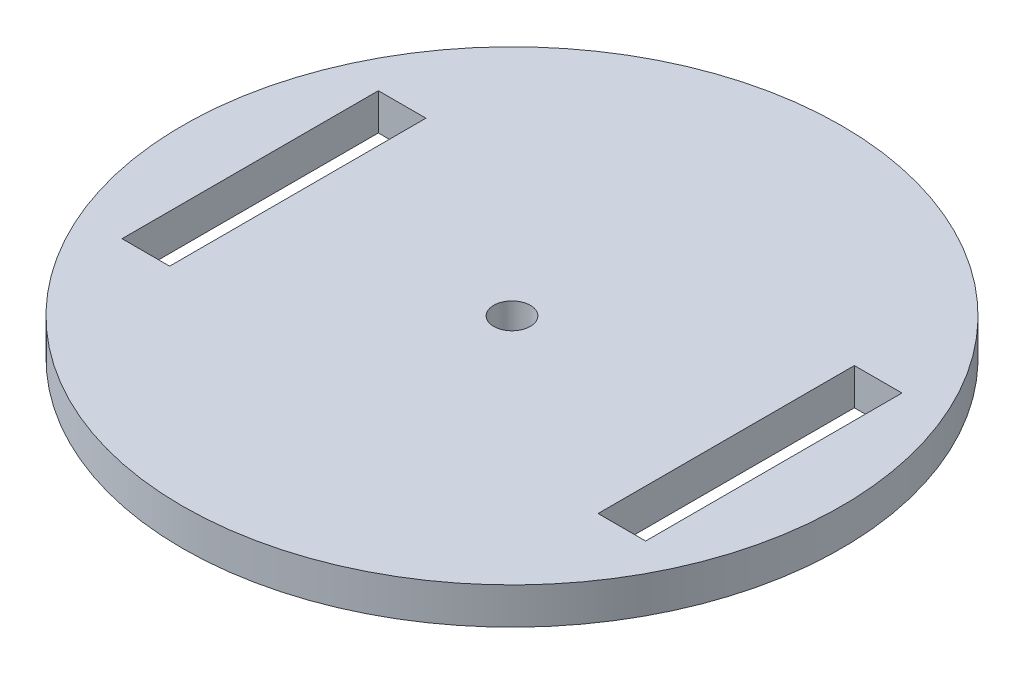
from build123d import *

# Parameters (mm, degrees)
SKETCH1_R           = 90
SKETCH1_W           = 13
SKETCH1_H           = 70
BOSS_EXTRUDE1_DEPTH = 10
CUT_EXTRUDE1_REACH  = 12
SKETCH2_R           = 5


with BuildPart() as part:
    # Sketch1 → Boss-Extrude1 (new body)
    with BuildSketch(Plane(origin=(0, 0, 0), x_dir=(1, 0, 0), z_dir=(0, 1, 0))):
        Circle(SKETCH1_R)
        with Locations((-65, 0)):
            Rectangle(SKETCH1_W, SKETCH1_H, mode=Mode.SUBTRACT)
        with Locations((65, 0)):
            Rectangle(SKETCH1_W, SKETCH1_H, mode=Mode.SUBTRACT)
    extrude(amount=BOSS_EXTRUDE1_DEPTH)

    # Sketch2 → Cut-Extrude1 (cut, up to next)
    with BuildSketch(Plane.XZ, mode=Mode.PRIVATE) as cut_extrude1_sk1:
        Circle(SKETCH2_R)
    cut_extrude1_tool1 = extrude(cut_extrude1_sk1.sketch, amount=-CUT_EXTRUDE1_REACH, mode=Mode.PRIVATE) & part.part
    add(cut_extrude1_tool1.solids().sort_by_distance((0, 0, 0))[0], mode=Mode.SUBTRACT)


solid = part.part
